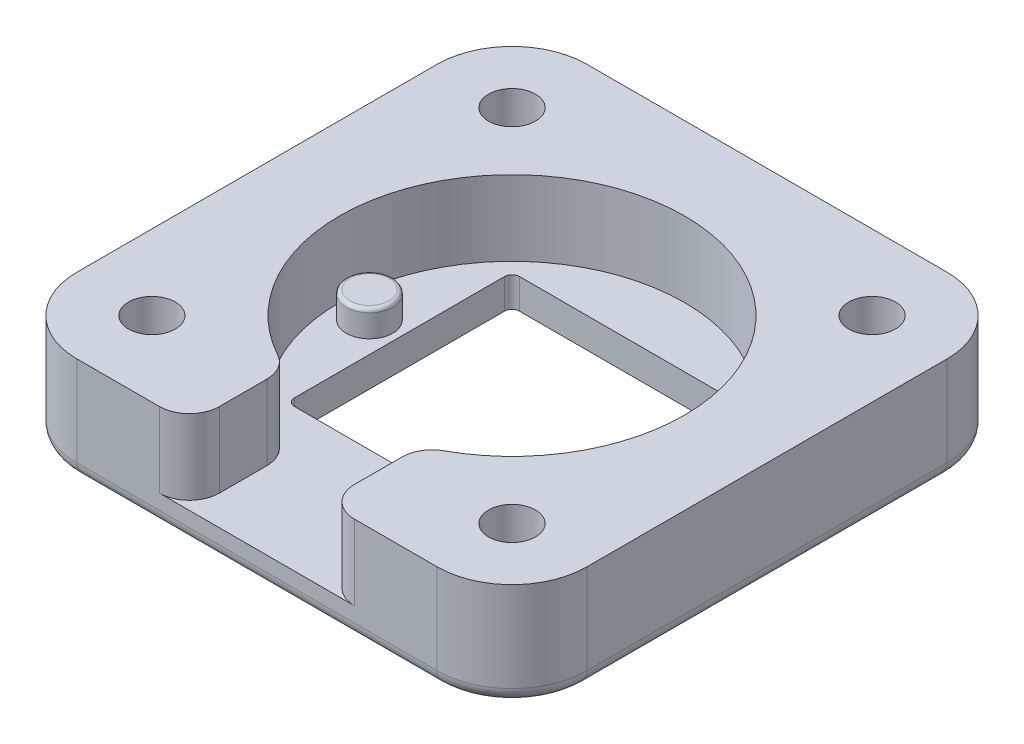
from build123d import *

# Parameters (mm, degrees)
SKETCH1_W           = 34
SKETCH1_H           = 34
BOSS_EXTRUDE1_DEPTH = 7
SKETCH2_R           = 11.5
CUT_EXTRUDE1_DEPTH  = 5
SKETCH3_R           = 1.5621
CUT_EXTRUDE2_DEPTH  = 8
SKETCH4_W           = 9
SKETCH4_H           = 12.899537492
CUT_EXTRUDE3_DEPTH  = 5
SKETCH5_R           = 2.6
CUT_EXTRUDE4_DEPTH  = 4
FILLET1_R           = 5
FILLET2_R           = 1
FILLET3_R           = 2
SKETCH6_W           = 15
SKETCH6_H           = 15
CUT_EXTRUDE5_DEPTH  = 2
SKETCH7_R           = 1.55
BOSS_EXTRUDE3_DEPTH = 1.75
FILLET5_R           = 0.25
FILLET6_R           = 0.5


with BuildPart() as part:
    # Sketch1 → Boss-Extrude1 (new body)
    with BuildSketch(Plane(origin=(0, 0, 0), x_dir=(1, 0, 0), z_dir=(0, 1, 0))):
        with Locations((-0.609342113, -3.800882142)):
            Rectangle(SKETCH1_W, SKETCH1_H)
    extrude(amount=BOSS_EXTRUDE1_DEPTH)

    # Sketch2 → Cut-Extrude1 (cut)
    with BuildSketch(Plane(origin=(0, 7, 0), x_dir=(1, 0, 0), z_dir=(0, 1, 0))):
        with Locations((-0.609342113, -3.800882142)):
            Circle(SKETCH2_R)
    extrude(amount=-CUT_EXTRUDE1_DEPTH, mode=Mode.SUBTRACT)

    # Sketch3 → Cut-Extrude2 (cut, through all)
    with BuildSketch(Plane(origin=(0, 7, 0), x_dir=(1, 0, 0), z_dir=(0, 1, 0))):
        with Locations((-12.609342113, 8.199117858)):
            Circle(SKETCH3_R)
        with Locations((-12.609342113, -15.800882142)):
            Circle(SKETCH3_R)
        with Locations((11.390657887, -15.800882142)):
            Circle(SKETCH3_R)
        with Locations((11.390657887, 8.199117858)):
            Circle(SKETCH3_R)
    extrude(amount=-CUT_EXTRUDE2_DEPTH, mode=Mode.SUBTRACT)

    # Sketch4 → Cut-Extrude3 (cut)
    with BuildSketch(Plane(origin=(0, 7, 0), x_dir=(1, 0, 0), z_dir=(0, 1, 0))):
        with Locations((-0.609342113, -16.792376967)):
            Rectangle(SKETCH4_W, SKETCH4_H)
    extrude(amount=-CUT_EXTRUDE3_DEPTH, mode=Mode.SUBTRACT)

    # Sketch5 → Cut-Extrude4 (cut)
    with BuildSketch(Plane.XZ):
        with Locations((-12.609342113, 15.800882142)):
            Circle(SKETCH5_R)
        with Locations((11.390657887, 15.800882142)):
            Circle(SKETCH5_R)
        with Locations((-12.609342113, -8.199117858)):
            Circle(SKETCH5_R)
        with Locations((11.390657887, -8.199117858)):
            Circle(SKETCH5_R)
    extrude(amount=-CUT_EXTRUDE4_DEPTH, mode=Mode.SUBTRACT)

    # Fillet1
    fillet1_edges = [part.edges().sort_by_distance(p)[0] for p in [
        (-17.609342113, 3.5, -13.199117858),
        (16.390657887, 3.5, -13.199117858),
        (16.390657887, 3.5, 20.800882142),
        (-17.609342113, 3.5, 20.800882142),
    ]]
    fillet(fillet1_edges, radius=FILLET1_R)

    # Fillet2
    fillet2_edges = [part.edges().sort_by_distance(p)[0] for p in [
        (-15.209342113, 0, 15.800882142),
        (8.790657887, 0, 15.800882142),
        (-15.209342113, 0, -8.199117858),
        (8.790657887, 0, -8.199117858),
        (16.390657887, 0, 3.800882142),
        (-17.609342113, 0, 3.800882142),
        (-0.609342113, 0, -13.199117858),
        (-0.609342113, 0, 20.800882142),
        (-16.144876019, 0, 19.336416048),
        (-16.144876019, 0, -11.734651764),
        (14.926191793, 0, -11.734651764),
        (14.926191793, 0, 19.336416048),
    ]]
    fillet(fillet2_edges, radius=FILLET2_R)

    # Fillet3
    fillet3_edges = [part.edges().sort_by_distance(p)[0] for p in [
        (-5.109342113, 4.5, 20.800882142),
        (-5.109342113, 4.5, 14.383887386),
        (3.890657887, 4.5, 20.800882142),
        (3.890657887, 4.5, 14.383887386),
    ]]
    fillet(fillet3_edges, radius=FILLET3_R)

    # Sketch6 → Cut-Extrude5 (cut)
    with BuildSketch(Plane.XZ):
        with Locations((-0.609342113, 3.800882142)):
            Rectangle(SKETCH6_W, SKETCH6_H)
    extrude(amount=-CUT_EXTRUDE5_DEPTH, mode=Mode.SUBTRACT)

    # Sketch7 → Boss-Extrude3 (add)
    with BuildSketch(Plane(origin=(0, 2, 0), x_dir=(1, 0, 0), z_dir=(0, 1, 0))):
        with Locations((8.890657887, -3.800882142)):
            Circle(SKETCH7_R)
        with Locations((-10.109342113, -3.800882142)):
            Circle(SKETCH7_R)
    extrude(amount=BOSS_EXTRUDE3_DEPTH)

    # Fillet5
    fillet5_edges = [part.edges().sort_by_distance(p)[0] for p in [
        (7.340657887, 3.75, 3.800882142),
        (-11.659342113, 3.75, 3.800882142),
    ]]
    fillet(fillet5_edges, radius=FILLET5_R)

    # Fillet6
    fillet6_edges = [part.edges().sort_by_distance(p)[0] for p in [
        (-8.109342113, 1, -3.699117858),
        (-8.109342113, 1, 11.300882142),
        (6.890657887, 1, 11.300882142),
        (6.890657887, 1, -3.699117858),
    ]]
    fillet(fillet6_edges, radius=FILLET6_R)


solid = part.part
